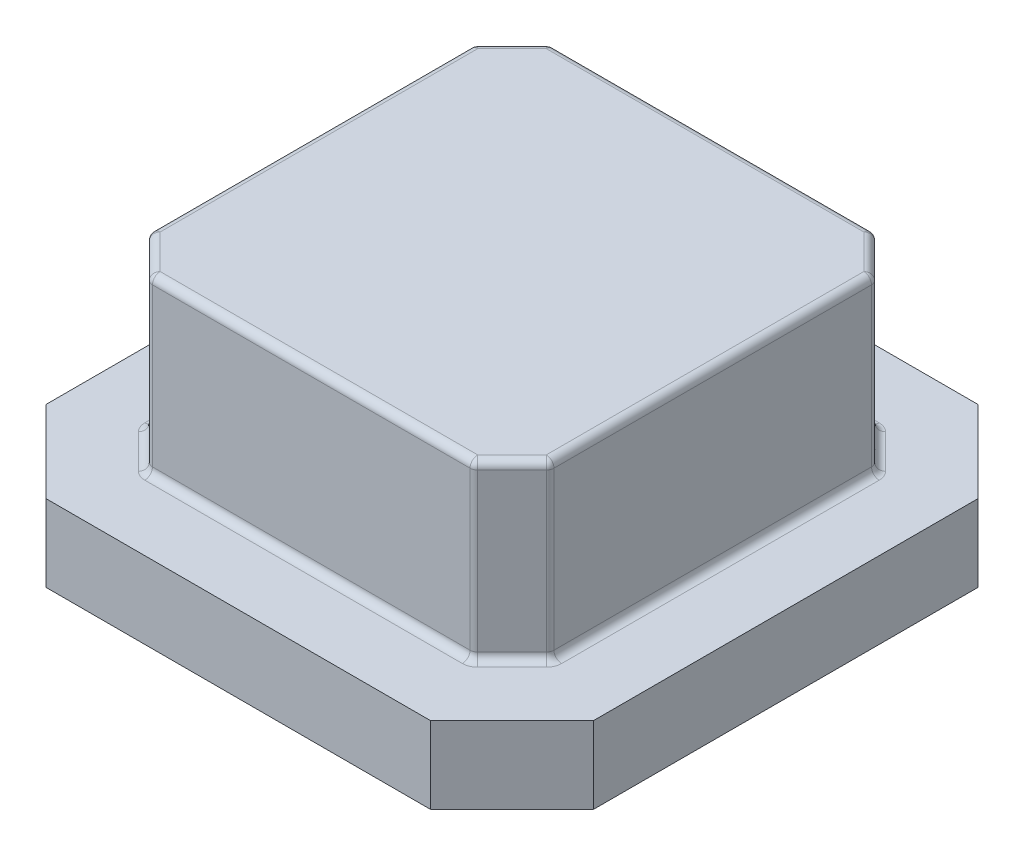
from build123d import *

# Parameters (mm, degrees)
BOSS_EXTRUDE1_DEPTH = 25.4
BOSS_EXTRUDE2_DEPTH = 57.15
FILLET1_R           = 2.54


with BuildPart() as part:
    # Sketch2 → Boss-Extrude1 (new body)
    with BuildSketch(Plane(origin=(0, 0, 0), x_dir=(1, 0, 0), z_dir=(0, 1, 0))):
        Polygon((-56.661538462, 0), (70.338461538, 0), (97.279229902, 26.940768363), (97.279229902, 153.940768363), (70.338461538, 180.881536726), (-56.661538462, 180.881536726), (-83.602306825, 153.940768363), (-83.602306825, 26.940768363), align=None)
    extrude(amount=BOSS_EXTRUDE1_DEPTH)

    # Sketch3 → Boss-Extrude2 (add)
    with BuildSketch(Plane(origin=(0, 25.4, 0), x_dir=(1, 0, 0), z_dir=(0, 1, 0))):
        Polygon((-59.472306825, 36.935741623), (-46.666565201, 24.13), (60.343488278, 24.13), (73.149229902, 36.935741623), (73.149229902, 143.945795103), (60.343488278, 156.751536726), (-46.666565201, 156.751536726), (-59.472306825, 143.945795103), align=None)
    extrude(amount=BOSS_EXTRUDE2_DEPTH)

    # Fillet1
    fillet1_edges = [part.edges().sort_by_distance(p)[0] for p in [
        (-59.472306825, 25.4, -90.440768363),
        (-59.472306825, 53.975, -143.945795103),
        (-53.069436013, 25.4, -30.532870812),
        (-59.472306825, 53.975, -36.935741623),
        (6.838461538, 25.4, -24.13),
        (-46.666565201, 53.975, -24.13),
        (66.74635909, 25.4, -30.532870812),
        (60.343488278, 53.975, -24.13),
        (73.149229902, 25.4, -90.440768363),
        (73.149229902, 53.975, -36.935741623),
        (66.74635909, 25.4, -150.348665915),
        (73.149229902, 53.975, -143.945795103),
        (6.838461538, 25.4, -156.751536726),
        (60.343488278, 53.975, -156.751536726),
        (-53.069436013, 25.4, -150.348665915),
        (-46.666565201, 53.975, -156.751536726),
        (-59.472306825, 82.55, -90.440768363),
        (-53.069436013, 82.55, -30.532870812),
        (6.838461538, 82.55, -24.13),
        (66.74635909, 82.55, -30.532870812),
        (73.149229902, 82.55, -90.440768363),
        (66.74635909, 82.55, -150.348665915),
        (6.838461538, 82.55, -156.751536726),
        (-53.069436013, 82.55, -150.348665915),
    ]]
    fillet(fillet1_edges, radius=FILLET1_R)


solid = part.part
